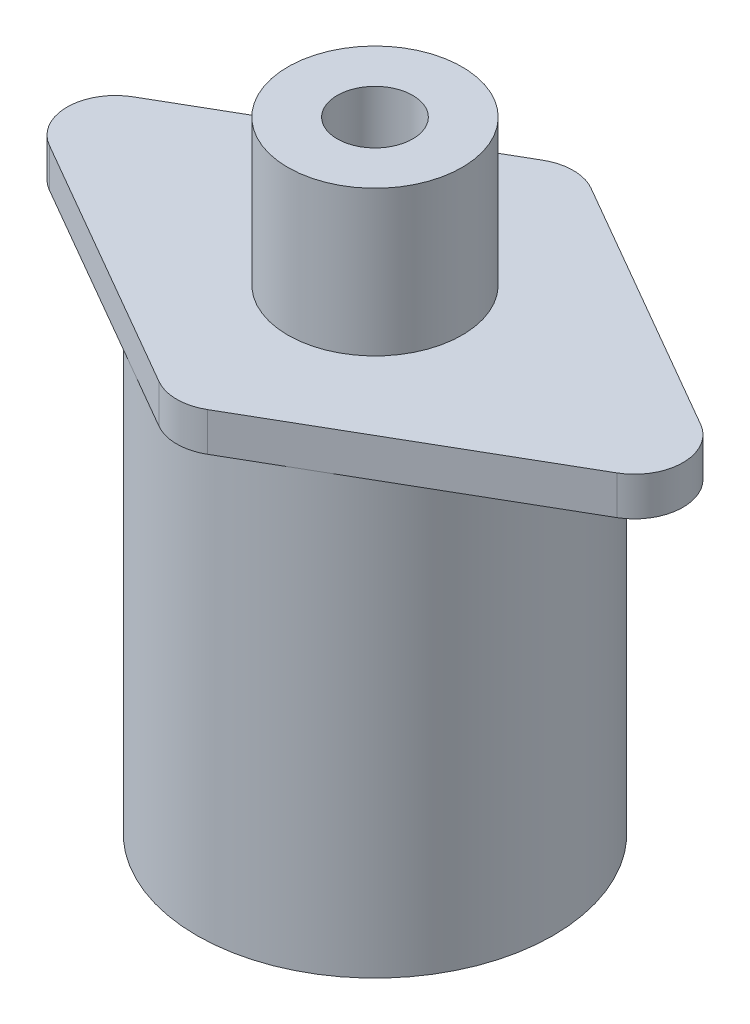
from build123d import *

# Parameters (mm, degrees)
SKETCH1_R           = 18.4
BOSS_EXTRUDE1_DEPTH = 45
BOSS_EXTRUDE2_DEPTH = 4
FILLET1_R           = 5
SKETCH3_R           = 9
BOSS_EXTRUDE3_DEPTH = 15
SKETCH4_R           = 3.9
CUT_EXTRUDE1_DEPTH  = 10


with BuildPart() as part:
    # Sketch1 → Boss-Extrude1 (new body)
    with BuildSketch(Plane(origin=(0, 0, 0), x_dir=(1, 0, 0), z_dir=(0, 1, 0))):
        Circle(SKETCH1_R)
    extrude(amount=BOSS_EXTRUDE1_DEPTH)

    # Sketch2 → Boss-Extrude2 (add)
    with BuildSketch(Plane(origin=(0, 45, 0), x_dir=(1, 0, 0), z_dir=(0, 1, 0))):
        Polygon((0, 21.25), (-36.806079661, 0), (0, -21.25), (36.806079661, 0), align=None)
    extrude(amount=BOSS_EXTRUDE2_DEPTH)

    # Fillet1
    fillet1_edges = [part.edges().sort_by_distance(p)[0] for p in [
        (36.806079661, 47, 0),
        (0, 47, -21.25),
        (-36.806079661, 47, 0),
        (0, 47, 21.25),
    ]]
    fillet(fillet1_edges, radius=FILLET1_R)

    # Sketch3 → Boss-Extrude3 (add)
    with BuildSketch(Plane(origin=(0, 49, 0), x_dir=(1, 0, 0), z_dir=(0, 1, 0))):
        Circle(SKETCH3_R)
    extrude(amount=BOSS_EXTRUDE3_DEPTH)

    # Sketch4 → Cut-Extrude1 (cut)
    with BuildSketch(Plane(origin=(0, 64, 0), x_dir=(1, 0, 0), z_dir=(0, 1, 0))):
        Circle(SKETCH4_R)
    extrude(amount=-CUT_EXTRUDE1_DEPTH, mode=Mode.SUBTRACT)


solid = part.part
